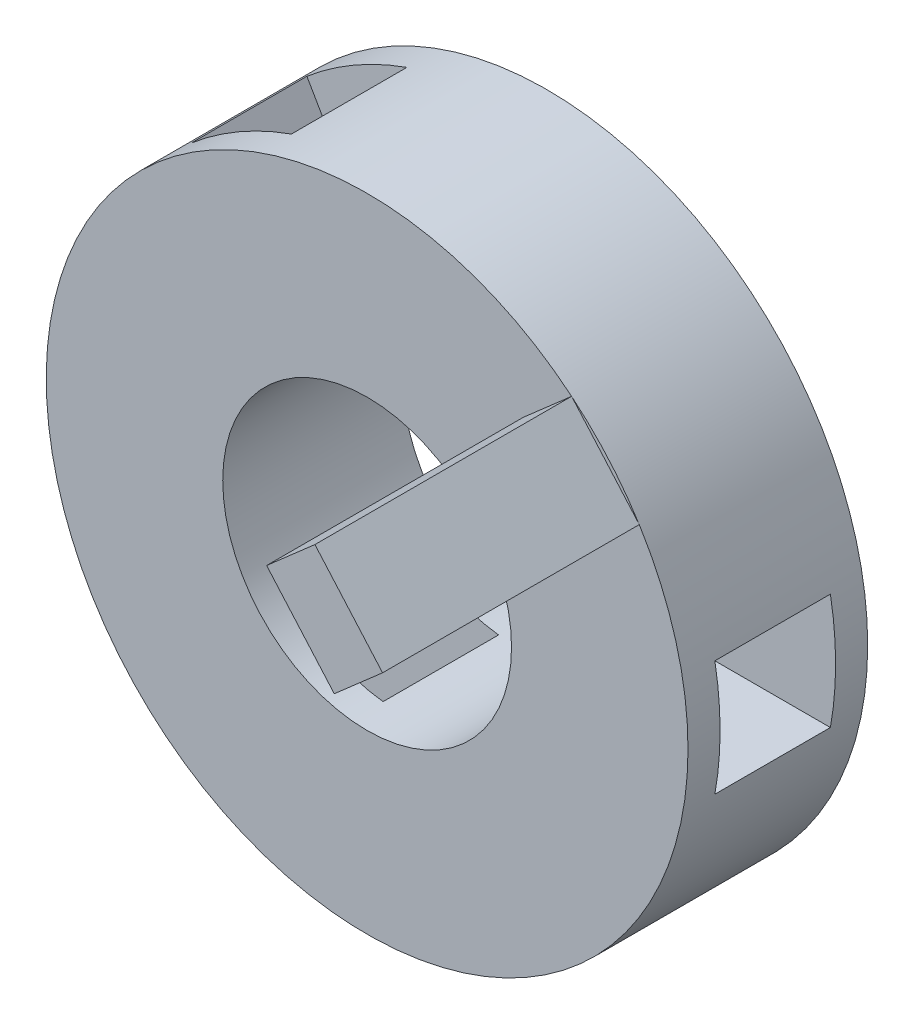
from build123d import *

# Parameters (mm, degrees)
ESQUISSE1_R                  = 25
BOSS_EXTRU_1_DEPTH           = 14
ENL_V_START                  = 26
ESQUISSE2_W                  = 9
ESQUISSE2_H                  = 9
ENL_V_MAT_EXTRU_1_DEPTH      = 16
R_P_TITION_CIRCULAIRE1_COUNT = 3
ESQUISSE9_R                  = 11.25
ENL_V_MAT_EXTRU_2_DEPTH      = 16
BOSS_EXTRU_3_START           = -14
BOSS_EXTRU_3_DEPTH           = 20


with BuildPart() as part:
    # Esquisse1 → Boss.-Extru.1 (new body)
    with BuildSketch(Plane.XY):
        Circle(ESQUISSE1_R)
    extrude(amount=BOSS_EXTRU_1_DEPTH)

    # Esquisse2 → Enlèv. mat.-Extru.1 (cut)
    with BuildSketch(Plane(origin=(0, 0, 0), x_dir=(0, 0, -1), z_dir=(1, 0, 0)).offset(ENL_V_START)):
        with Locations((-7, 0)):
            Rectangle(ESQUISSE2_W, ESQUISSE2_H)
    enl_v_mat_extru_1 = extrude(amount=-ENL_V_MAT_EXTRU_1_DEPTH, mode=Mode.SUBTRACT)

    # Répétition circulaire1: Enlèv. mat.-Extru.1 ×3 about axis
    r_p_tition_circulaire1_axis = Axis((0, 0, 0), (0, 0, 1))
    for i in range(1, R_P_TITION_CIRCULAIRE1_COUNT):
        add(enl_v_mat_extru_1.rotate(r_p_tition_circulaire1_axis, i * 360 / R_P_TITION_CIRCULAIRE1_COUNT), mode=Mode.SUBTRACT)

    # Esquisse9 → Enlèv. mat.-Extru.2 (cut)
    with BuildSketch(Plane(origin=(0, 0, 0), x_dir=(-1, 0, 0), z_dir=(0, 0, -1))):
        Circle(ESQUISSE9_R)
    extrude(amount=-ENL_V_MAT_EXTRU_2_DEPTH, mode=Mode.SUBTRACT)

    # Esquisse10 → Boss.-Extru.3 (add)
    with BuildSketch(Plane(origin=(0, 0, 0), x_dir=(-1, 0, 0), z_dir=(0, 0, -1)).offset(BOSS_EXTRU_3_START)):
        Polygon((-15.932437345, 19.265446796), (-21.202216656, 13.246358325), (-17.440286362, 9.952746256), (-12.170507051, 15.971834726), align=None)
    extrude(amount=-BOSS_EXTRU_3_DEPTH)


solid = part.part
